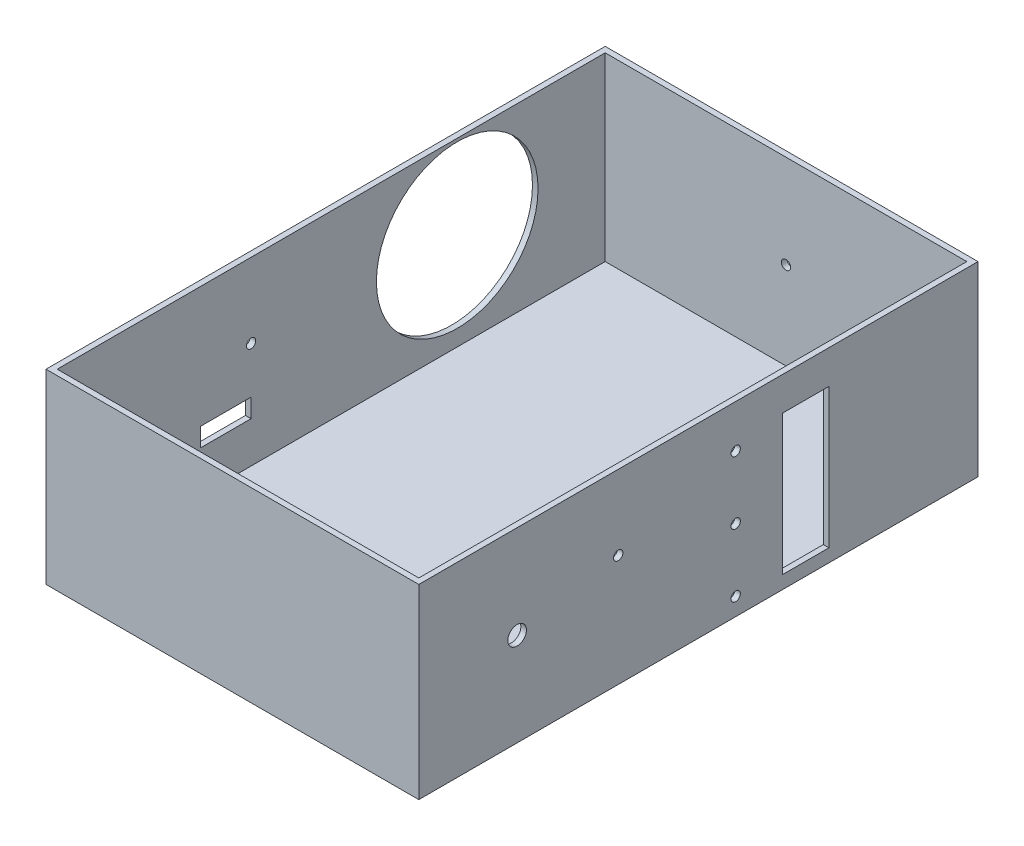
from build123d import *

# Parameters (mm, degrees)
ESBO_O1_W                = 200
ESBO_O1_H                = 100
RESSALTO_EXTRUS_O1_DEPTH = 150
ESBO_O2_W                = 194
ESBO_O2_H                = 294
CORTE_EXTRUS_O1_DEPTH    = 97
ESBO_O5_R                = 5
CORTE_EXTRUS_O4_DEPTH    = 10
ESBO_O7_R                = 2.5
CORTE_EXTRUS_O6_DEPTH    = 10
ESBO_O8_W                = 27
ESBO_O8_H                = 10
CORTE_EXTRUS_O9_DEPTH    = 10
ESBO_O11_R               = 2.5
CORTE_EXTRUS_O12_DEPTH   = 201
ESBO_O12_R               = 2.5
ESBO_O12_W               = 25
ESBO_O12_H               = 75
CORTE_EXTRUS_O13_DEPTH   = 10
ESBO_O13_R               = 43.358301647
CORTE_EXTRUS_O14_DEPTH   = 10


with BuildPart() as part:
    # Esboço1 → Ressalto-extrusão1 (new body, symmetric)
    with BuildSketch(Plane.XY):
        Rectangle(ESBO_O1_W, ESBO_O1_H)
    extrude(amount=RESSALTO_EXTRUS_O1_DEPTH, both=True)

    # Esboço2 → Corte-extrusão1 (cut)
    with BuildSketch(Plane(origin=(0, 50, 0), x_dir=(1, 0, 0), z_dir=(0, 1, 0))):
        Rectangle(ESBO_O2_W, ESBO_O2_H)
    extrude(amount=-CORTE_EXTRUS_O1_DEPTH, mode=Mode.SUBTRACT)

    # Esboço5 → Corte-extrusão4 (cut)
    with BuildSketch(Plane(origin=(100, 0, 0), x_dir=(0, 0, -1), z_dir=(1, 0, 0))):
        with Locations((-97.256103524, 0)):
            Circle(ESBO_O5_R)
    extrude(amount=-CORTE_EXTRUS_O4_DEPTH, mode=Mode.SUBTRACT)

    # Esboço7 → Corte-extrusão6 (cut)
    with BuildSketch(Plane(origin=(0, 0, -150), x_dir=(-1, 0, 0), z_dir=(0, 0, -1))):
        Circle(ESBO_O7_R)
    extrude(amount=-CORTE_EXTRUS_O6_DEPTH, mode=Mode.SUBTRACT)

    # Esboço8 → Corte-extrusão9 (cut)
    with BuildSketch(Plane.ZY.offset(100)):
        with Locations((56.5, -20)):
            Rectangle(ESBO_O8_W, ESBO_O8_H)
    extrude(amount=-CORTE_EXTRUS_O9_DEPTH, mode=Mode.SUBTRACT)

    # Esboço11 → Corte-extrusão12 (cut, through all)
    with BuildSketch(Plane.ZY.offset(100)):
        with Locations((43, 10)):
            Circle(ESBO_O11_R)
    extrude(amount=-CORTE_EXTRUS_O12_DEPTH, mode=Mode.SUBTRACT)

    # Esboço12 → Corte-extrusão13 (cut)
    with BuildSketch(Plane(origin=(100, 0, 0), x_dir=(0, 0, -1), z_dir=(1, 0, 0))):
        with Locations((20, 27)):
            Circle(ESBO_O12_R)
        with Locations((20, -6.75)):
            Circle(ESBO_O12_R)
        with Locations((20, -40.5)):
            Circle(ESBO_O12_R)
        with Locations((57.5, -5.5)):
            Rectangle(ESBO_O12_W, ESBO_O12_H)
    extrude(amount=-CORTE_EXTRUS_O13_DEPTH, mode=Mode.SUBTRACT)

    # Esboço13 → Corte-extrusão14 (cut)
    with BuildSketch(Plane.ZY.offset(100)):
        with Locations((-67.620059567, 5)):
            Circle(ESBO_O13_R)
    extrude(amount=-CORTE_EXTRUS_O14_DEPTH, mode=Mode.SUBTRACT)


solid = part.part
